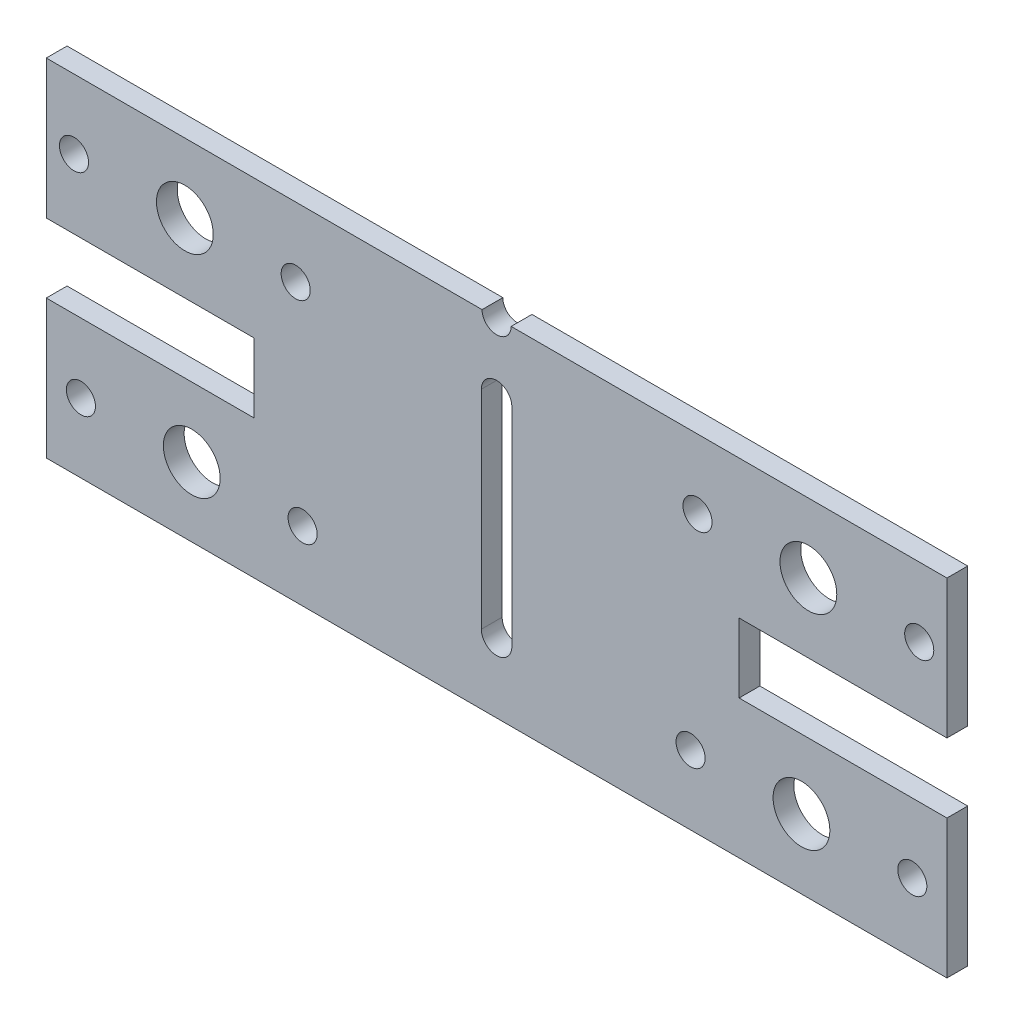
from build123d import *

# Parameters (mm, degrees)
ESQUISSE1_W             = 130
ESQUISSE1_H             = 50
ESQUISSE1_R             = 2.1
ESQUISSE1_R_2           = 4.1
BOSS_EXTRU_1_DEPTH      = 3
ENL_V_MAT_EXTRU_1_REACH = 5
ESQUISSE2_W             = 30
ESQUISSE2_H             = 10


with BuildPart() as part:
    # Esquisse1 → Boss.-Extru.1 (new body)
    with BuildSketch(Plane.XY):
        with Locations((65, 25)):
            Rectangle(ESQUISSE1_W, ESQUISSE1_H)
        with Locations((4, 40)):
            Circle(ESQUISSE1_R, mode=Mode.SUBTRACT)
        with Locations((20, 40)):
            Circle(ESQUISSE1_R_2, mode=Mode.SUBTRACT)
        with Locations((36, 40)):
            Circle(ESQUISSE1_R, mode=Mode.SUBTRACT)
        with Locations((94, 40)):
            Circle(ESQUISSE1_R, mode=Mode.SUBTRACT)
        with Locations((110, 40)):
            Circle(ESQUISSE1_R_2, mode=Mode.SUBTRACT)
        with Locations((126, 40)):
            Circle(ESQUISSE1_R, mode=Mode.SUBTRACT)
        with Locations((5, 10)):
            Circle(ESQUISSE1_R, mode=Mode.SUBTRACT)
        with Locations((21, 10)):
            Circle(ESQUISSE1_R_2, mode=Mode.SUBTRACT)
        with Locations((37, 10)):
            Circle(ESQUISSE1_R, mode=Mode.SUBTRACT)
        with Locations((93, 10)):
            Circle(ESQUISSE1_R, mode=Mode.SUBTRACT)
        with Locations((109, 10)):
            Circle(ESQUISSE1_R_2, mode=Mode.SUBTRACT)
        with Locations((125, 10)):
            Circle(ESQUISSE1_R, mode=Mode.SUBTRACT)
        with BuildLine():
            Line((62.8, 10), (62.8, 40))
            ThreePointArc((62.8, 40), (65, 42.2), (67.2, 40))
            Line((67.2, 40), (67.2, 10))
            ThreePointArc((67.2, 10), (65, 7.8), (62.8, 10))
        make_face(mode=Mode.SUBTRACT)
    extrude(amount=BOSS_EXTRU_1_DEPTH)

    # Esquisse2 → Enlèv. mat.-Extru.1 (cut, up to next)
    with BuildSketch(Plane(origin=(0, 0, 0), x_dir=(-1, 0, 0), z_dir=(0, 0, -1)), mode=Mode.PRIVATE) as enl_v_mat_extru_1_sk1:
        with Locations((-15, 25)):
            Rectangle(ESQUISSE2_W, ESQUISSE2_H)
    enl_v_mat_extru_1_tool1 = extrude(enl_v_mat_extru_1_sk1.sketch, amount=-ENL_V_MAT_EXTRU_1_REACH, mode=Mode.PRIVATE) & part.part
    add(enl_v_mat_extru_1_tool1.solids().sort_by_distance((15, 25, 0))[0], mode=Mode.SUBTRACT)
    # Esquisse2 → Enlèv. mat.-Extru.1 (cut, up to next)
    with BuildSketch(Plane(origin=(0, 0, 0), x_dir=(-1, 0, 0), z_dir=(0, 0, -1)), mode=Mode.PRIVATE) as enl_v_mat_extru_1_sk2:
        with Locations((-115, 25)):
            Rectangle(ESQUISSE2_W, ESQUISSE2_H)
    enl_v_mat_extru_1_tool2 = extrude(enl_v_mat_extru_1_sk2.sketch, amount=-ENL_V_MAT_EXTRU_1_REACH, mode=Mode.PRIVATE) & part.part
    add(enl_v_mat_extru_1_tool2.solids().sort_by_distance((115, 25, 0))[0], mode=Mode.SUBTRACT)
    # Esquisse2 → Enlèv. mat.-Extru.1 (cut, up to next)
    with BuildSketch(Plane(origin=(0, 0, 0), x_dir=(-1, 0, 0), z_dir=(0, 0, -1)), mode=Mode.PRIVATE) as enl_v_mat_extru_1_sk3:
        with BuildLine():
            Line((-62.9, 50), (-67.1, 50))
            ThreePointArc((-67.1, 50), (-65, 47.9), (-62.9, 50))
        make_face()
    enl_v_mat_extru_1_tool3 = extrude(enl_v_mat_extru_1_sk3.sketch, amount=-ENL_V_MAT_EXTRU_1_REACH, mode=Mode.PRIVATE) & part.part
    add(enl_v_mat_extru_1_tool3.solids().sort_by_distance((65, 49.108732, 0))[0], mode=Mode.SUBTRACT)


solid = part.part
